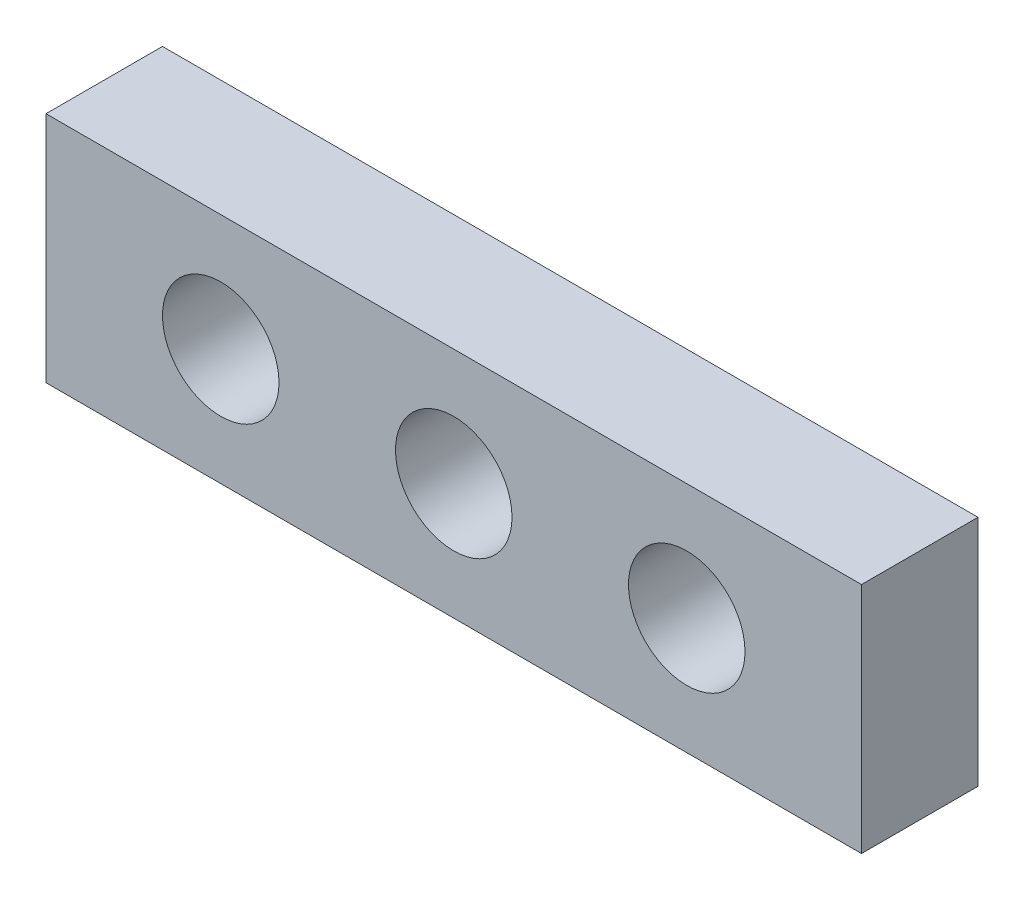
from build123d import *

# Parameters (mm, degrees)
SKETCH1_W           = 140
SKETCH1_H           = 40
SKETCH1_R           = 10
BOSS_EXTRUDE1_DEPTH = 20


with BuildPart() as part:
    # Sketch1 → Boss-Extrude1 (new body)
    with BuildSketch(Plane.XY):
        with Locations((70, 20)):
            Rectangle(SKETCH1_W, SKETCH1_H)
        with Locations((30, 20)):
            Circle(SKETCH1_R, mode=Mode.SUBTRACT)
        with Locations((70, 20)):
            Circle(SKETCH1_R, mode=Mode.SUBTRACT)
        with Locations((110, 20)):
            Circle(SKETCH1_R, mode=Mode.SUBTRACT)
    extrude(amount=-BOSS_EXTRUDE1_DEPTH)


solid = part.part
